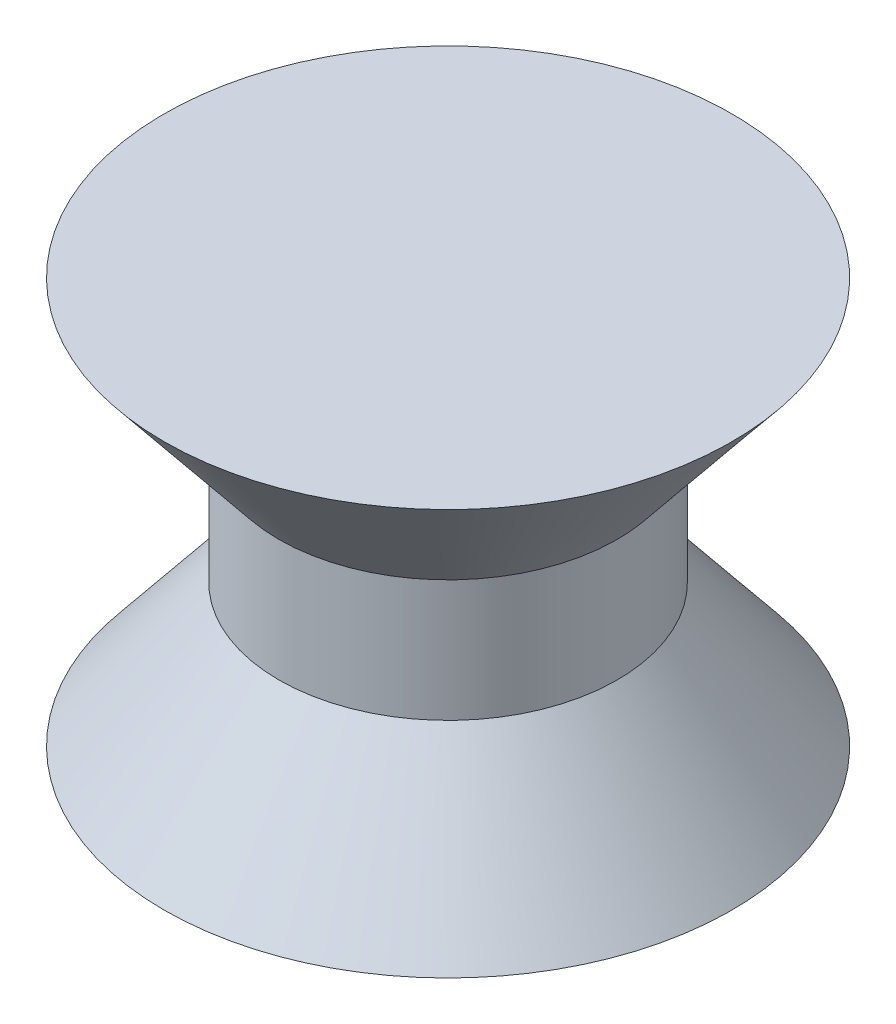
from build123d import *

# Parameters (mm, degrees)
CROQUIS2_R            = 1.5
CORTAR_EXTRUIR1_DEPTH = 2


with BuildPart() as part:
    # Croquis1 → Revolución3 (revolve)
    with BuildSketch(Plane.XY):
        Polygon((0, 5), (0, -5), (7, -5), (4.172417728, -1.5), (4.172417728, 1.5), (7, 5), align=None)
    revolve(axis=Axis((0, 14.056584816, 0), (0, -1, 0)))

    # Croquis2 → Cortar-Extruir1 (cut)
    with BuildSketch(Plane(origin=(0, -5, 0), x_dir=(-1, 0, 0), z_dir=(0, -1, 0))):
        Circle(CROQUIS2_R)
    extrude(amount=-CORTAR_EXTRUIR1_DEPTH, mode=Mode.SUBTRACT)


solid = part.part
